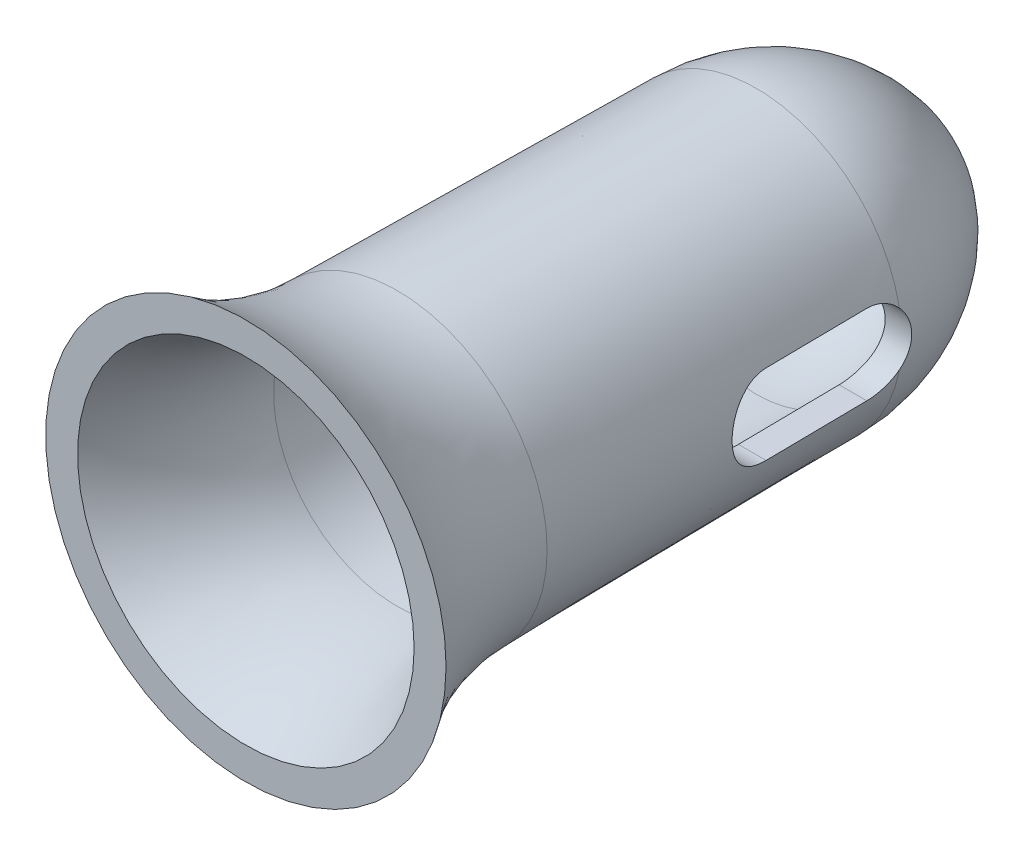
from build123d import *

# Parameters (mm, degrees)
SIDECONNECTIONCUTOUT_DEPTH      = 73.071040696
SIDECONNECTIONCUTOUT_DEPTH_BACK = 73.071040696


with BuildPart() as part:
    # ProfileS → Profile (revolve)
    with BuildSketch(Plane(origin=(0, 0, 0), x_dir=(1, 0, 0), z_dir=(0, 1, 0))):
        with BuildLine():
            Line((10, 58.044891829), (10.291196376, 33.398198054))
            ThreePointArc((10.291196376, 33.398198054), (11.210065487, 27.929487559), (13.75, 23))
            Line((13.75, 23), (11.555755546, 23))
            ThreePointArc((11.555755546, 23), (9.29389864, 27.974053085), (8.476604376, 33.376758967))
            Line((8.476604376, 33.376758967), (8.185408, 58.023452742))
            ThreePointArc((8.185408, 58.023452742), (6.786696454, 63.308767571), (3.05, 67.299763243))
            Line((3.05, 67.299763243), (3.05, 69.398198054))
            ThreePointArc((3.05, 69.398198054), (8.088410722, 64.678596949), (10, 58.044891829))
        make_face()
    revolve(axis=Axis((0, 0, -23), (0, 0, -1)))

    # SideConnectionCutoutS → SideConnectionCutout (cut, two sides: drawn at the far end of the back side and taken through both)
    with BuildSketch(Plane(origin=(0, 0, 0), x_dir=(0, 0, -1), z_dir=(1, 0, 0)).offset(-SIDECONNECTIONCUTOUT_DEPTH_BACK)):
        with BuildLine():
            Line((56, -2.75), (49, -2.75))
            ThreePointArc((49, -2.75), (46.25, 0), (49, 2.75))
            Line((49, 2.75), (56, 2.75))
            ThreePointArc((56, 2.75), (58.75, 0), (56, -2.75))
        make_face()
    extrude(amount=SIDECONNECTIONCUTOUT_DEPTH + SIDECONNECTIONCUTOUT_DEPTH_BACK, mode=Mode.SUBTRACT)


solid = part.part
